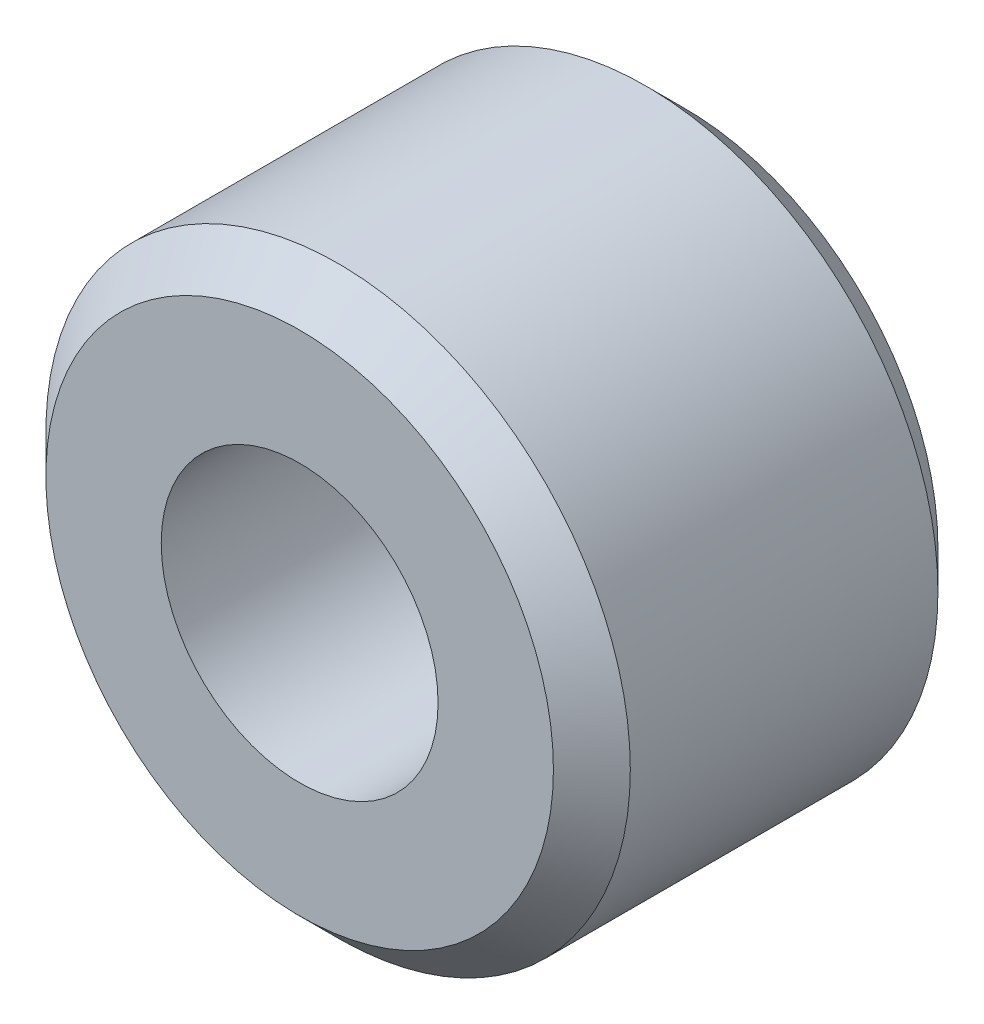
from build123d import *

# Parameters (mm, degrees)
SKETCH1_R           = 3.8
SKETCH1_R_2         = 1.8
BOSS_EXTRUDE1_DEPTH = 5
CHAMFER1_SIZE       = 0.5


with BuildPart() as part:
    # Sketch1 → Boss-Extrude1 (new body)
    with BuildSketch(Plane.XY):
        Circle(SKETCH1_R)
        Circle(SKETCH1_R_2, mode=Mode.SUBTRACT)
    extrude(amount=BOSS_EXTRUDE1_DEPTH)

    # Chamfer1
    chamfer1_edges = [part.edges().sort_by_distance(p)[0] for p in [
        (-3.8, 0, 0),
        (-3.8, 0, 5),
    ]]
    chamfer(chamfer1_edges, length=CHAMFER1_SIZE)


solid = part.part
